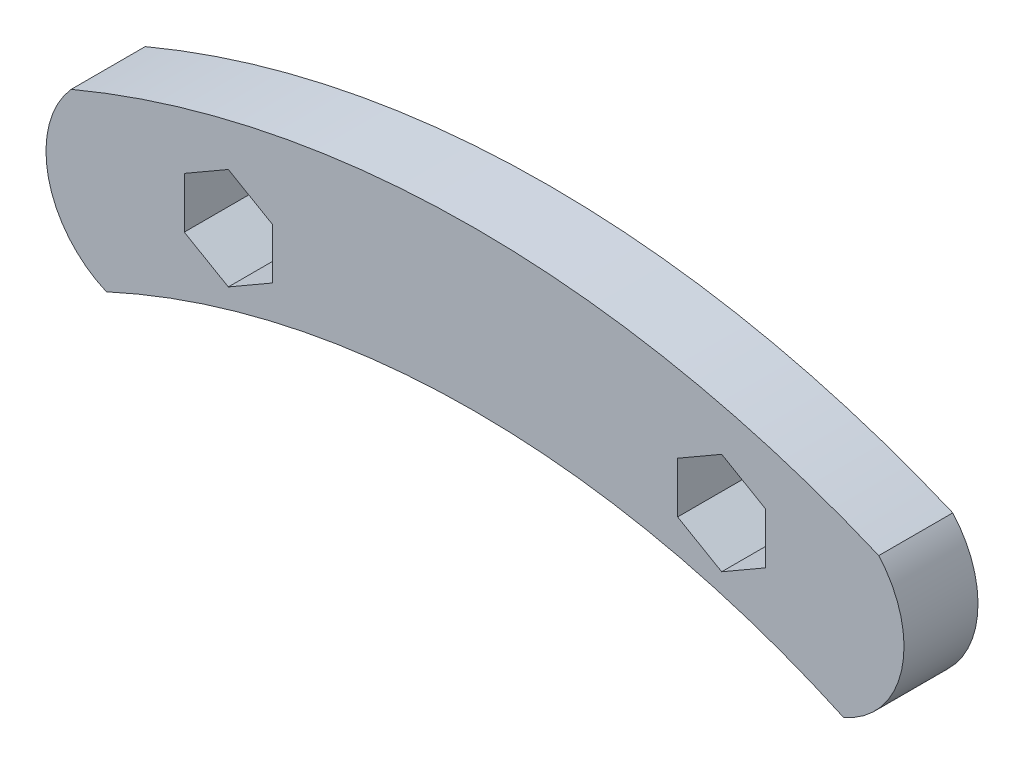
from build123d import *

# Parameters (mm, degrees)
BOSS_EXTRUDE1_DEPTH = 5.334


with BuildPart() as part:
    # Sketch1 → Boss-Extrude1 (new body)
    with BuildSketch(Plane.XY):
        with BuildLine():
            ThreePointArc((29.104915692, 69.046424835), (0, 74.93), (-29.104915692, 69.046424835))
            ThreePointArc((-29.104915692, 69.046424835), (-30.750210185, 62.710204346), (-26.565512441, 57.676022304))
            ThreePointArc((-26.565512441, 57.676022304), (0, 63.5), (26.565512441, 57.676022304))
            ThreePointArc((26.565512441, 57.676022304), (30.750210185, 62.710204346), (29.104915692, 69.046424835))
        make_face()
        Polygon((-17.78, 62.373825791), (-14.605, 64.206912895), (-14.605, 67.873087105), (-17.78, 69.706174209), (-20.955, 67.873087105), (-20.955, 64.206912895), align=None, mode=Mode.SUBTRACT)
        Polygon((17.78, 62.373825791), (20.955, 64.206912895), (20.955, 67.873087105), (17.78, 69.706174209), (14.605, 67.873087105), (14.605, 64.206912895), align=None, mode=Mode.SUBTRACT)
    extrude(amount=BOSS_EXTRUDE1_DEPTH)


solid = part.part
